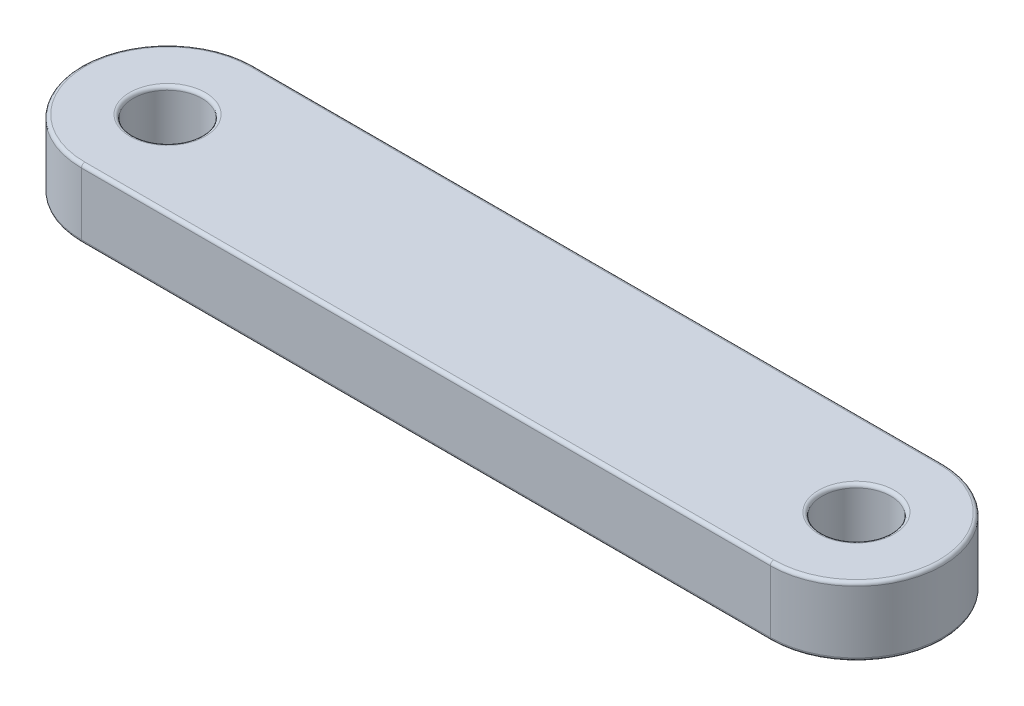
from build123d import *

# Parameters (mm, degrees)
SKETCH1_R           = 10
BOSS_EXTRUDE1_DEPTH = 20
FILLET1_R           = 1


with BuildPart() as part:
    # Sketch1 → Boss-Extrude1 (new body)
    with BuildSketch(Plane(origin=(0, 0, 0), x_dir=(1, 0, 0), z_dir=(0, 1, 0))):
        with BuildLine():
            Line((-100, 25), (100, 25))
            ThreePointArc((100, 25), (125, 0), (100, -25))
            Line((100, -25), (-100, -25))
            ThreePointArc((-100, -25), (-125, 0), (-100, 25))
        make_face()
        with Locations((-100, 0)):
            Circle(SKETCH1_R, mode=Mode.SUBTRACT)
        with Locations((100, 0)):
            Circle(SKETCH1_R, mode=Mode.SUBTRACT)
    extrude(amount=BOSS_EXTRUDE1_DEPTH)

    # Fillet1
    fillet1_edges = [part.edges().sort_by_distance(p)[0] for p in [
        (-110, 0, 0),
        (-110, 20, 0),
        (125, 20, 0),
        (90, 0, 0),
        (90, 20, 0),
        (0, 20, -25),
        (-125, 20, 0),
        (0, 0, -25),
        (125, 0, 0),
        (0, 0, 25),
        (-125, 0, 0),
        (0, 20, 25),
    ]]
    fillet(fillet1_edges, radius=FILLET1_R)


solid = part.part
